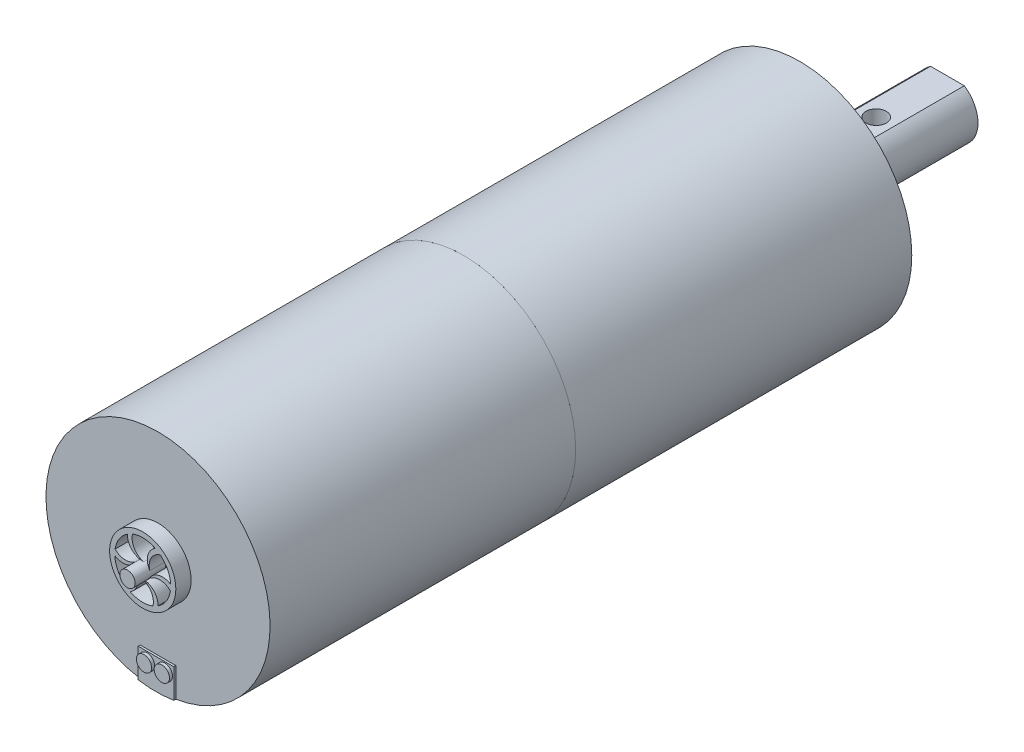
from build123d import *

# Parameters (mm, degrees)
ESQUISSE1_R                  = 11
ESQUISSE1_R_2                = 7.5
ESQUISSE1_R_3                = 1
BOSS_EXTRU_1_DEPTH           = 33
ESQUISSE1_R_4                = 4.25
BOSS_EXTRU_1_2_DEPTH         = 33
ESQUISSE1_3_R                = 4.25
BOSS_EXTRU_2_DEPTH           = 1.5
BOSS_EXTRU_3_DEPTH           = 2.5
BOSS_EXTRU_4_DEPTH           = 14.5
ESQUISSE1_7_R                = 7.5
ESQUISSE1_7_R_2              = 6.25
BOSS_EXTRU_5_DEPTH           = 1.5
ESQUISSE1_6_R                = 6.25
BOSS_EXTRU_6_DEPTH           = 1
ESQUISSE1_8_R                = 4.25
ESQUISSE1_8_R_2              = 3
BOSS_EXTRU_7_DEPTH           = 1.5
ENL_V_MAT_EXTRU_1_REACH      = 39.313
ENL_V_MAT_EXTRU_1_END_RADIUS = 3
ESQUISSE2_R                  = 1
ESQUISSE3_R                  = 11
BOSS_EXTRU_8_DEPTH           = 30
ESQUISSE3_2_R                = 11
BOSS_EXTRU_9_DEPTH           = 27
ESQUISSE4_R                  = 3.25
ESQUISSE4_R_2                = 2.75
BOSS_EXTRU_10_DEPTH          = 1.5
ESQUISSE5_R                  = 0.75
BOSS_EXTRU_11_DEPTH          = 1.5
CHANFREIN1_SIZE              = 0.5
ESQUISSE6_R                  = 0.75
BOSS_EXTRU_15_DEPTH          = 0.2
ESQUISSE6_4_R                = 0.75
BOSS_EXTRU_16_DEPTH          = 0.5
ESQUISSE6_5_R                = 0.75
BOSS_EXTRU_17_DEPTH          = 0.5


with BuildPart() as part:
    # Esquisse1 → Boss.-Extru.1 (new body)
    with BuildSketch(Plane.XY):
        Circle(ESQUISSE1_R)
        Circle(ESQUISSE1_R_2, mode=Mode.SUBTRACT)
        with Locations((0, 9.5)):
            Circle(ESQUISSE1_R_3, mode=Mode.SUBTRACT)
        with Locations((8.227241336, 4.75)):
            Circle(ESQUISSE1_R_3, mode=Mode.SUBTRACT)
        with Locations((8.227241336, -4.75)):
            Circle(ESQUISSE1_R_3, mode=Mode.SUBTRACT)
        with Locations((0, -9.5)):
            Circle(ESQUISSE1_R_3, mode=Mode.SUBTRACT)
        with Locations((-8.227241336, -4.75)):
            Circle(ESQUISSE1_R_3, mode=Mode.SUBTRACT)
        with Locations((-8.227241336, 4.75)):
            Circle(ESQUISSE1_R_3, mode=Mode.SUBTRACT)
    extrude(amount=BOSS_EXTRU_1_DEPTH)

    # Esquisse3_2 → Boss.-Extru.9 (add)
    with BuildSketch(Plane.XY.offset(33)):
        Circle(ESQUISSE3_2_R)
    extrude(amount=-BOSS_EXTRU_9_DEPTH)


with BuildPart() as body_2:
    # Esquisse1 → Boss.-Extru.1 2 (new body)
    with BuildSketch(Plane.XY):
        Circle(ESQUISSE1_R_4)
    extrude(amount=BOSS_EXTRU_1_2_DEPTH)


with BuildPart() as body_3:
    # Esquisse1_3 → Boss.-Extru.2 (new body)
    with BuildSketch(Plane.XY):
        Circle(ESQUISSE1_3_R)
    extrude(amount=-BOSS_EXTRU_2_DEPTH)



with BuildPart() as body_4:
    # Esquisse1_4 → Boss.-Extru.3 (new body)
    with BuildSketch(Plane.XY):
        with BuildLine():
            ThreePointArc((1.658312395, 2.5), (0, 3), (-1.658312395, 2.5))
            Line((-1.658312395, 2.5), (1.658312395, 2.5))
        make_face()
        with BuildLine():
            Line((1.658312395, 2.5), (-1.658312395, 2.5))
            ThreePointArc((-1.658312395, 2.5), (-1.418637165, -2.643382037), (3, 0))
            ThreePointArc((3, 0), (2.643382037, 1.418637165), (1.658312395, 2.5))
        make_face()
    extrude(amount=-BOSS_EXTRU_3_DEPTH)


with BuildPart() as body_5:
    # Esquisse1_5 → Boss.-Extru.4 (new body)
    with BuildSketch(Plane.XY):
        with BuildLine():
            Line((1.658312395, 2.5), (-1.658312395, 2.5))
            ThreePointArc((-1.658312395, 2.5), (-1.418637165, -2.643382037), (3, 0))
            ThreePointArc((3, 0), (2.643382037, 1.418637165), (1.658312395, 2.5))
        make_face()
    extrude(amount=-BOSS_EXTRU_4_DEPTH)


with BuildPart() as body_6:
    # Esquisse1_7 → Boss.-Extru.5 (new body)
    with BuildSketch(Plane.XY):
        Circle(ESQUISSE1_7_R)
        Circle(ESQUISSE1_7_R_2, mode=Mode.SUBTRACT)
    extrude(amount=-BOSS_EXTRU_5_DEPTH)

    # Chanfrein1
    chanfrein1_edges = [body_6.edges().sort_by_distance(p)[0] for p in [
        (-6.25, 0, -1.5),
    ]]
    chamfer(chanfrein1_edges, length=CHANFREIN1_SIZE)


with BuildPart() as body_3_1:
    add(body_3.part)

    add(body_4.part)  # Boss.-Extru.6 merges body 4

    add(body_5.part)  # Boss.-Extru.6 merges body 5

    add(body_2.part)  # Boss.-Extru.6 merges body 2
    # Esquisse1_6 → Boss.-Extru.6 (add)
    with BuildSketch(Plane.XY):
        Circle(ESQUISSE1_6_R)
    extrude(amount=-BOSS_EXTRU_6_DEPTH)

    # Enlèv. mat.-Extru.1: up to this cylinder (the profile starts inside it)
    enl_v_mat_extru_1_end = Plane(origin=(0, 0, -7.5), z_dir=(0, 0, 1)) * Cylinder(ENL_V_MAT_EXTRU_1_END_RADIUS, 85.626, mode=Mode.PRIVATE)
    # Esquisse2 → Enlèv. mat.-Extru.1 (cut, up to the surface)
    with BuildSketch(Plane(origin=(0, 2.5, 0), x_dir=(1, 0, 0), z_dir=(0, 1, 0)), mode=Mode.PRIVATE) as enl_v_mat_extru_1_sk1:
        with Locations(Location((0, 7.5, 0), (0, 0, 270))):
            Circle(ESQUISSE2_R)
    enl_v_mat_extru_1_tool1 = extrude(enl_v_mat_extru_1_sk1.sketch, amount=-ENL_V_MAT_EXTRU_1_REACH, mode=Mode.PRIVATE) & enl_v_mat_extru_1_end
    add(enl_v_mat_extru_1_tool1.solids().sort_by_distance((0, 2.5, -7.5))[0], mode=Mode.SUBTRACT)


with BuildPart() as body_4_2:
    # Esquisse1_8 → Boss.-Extru.7 (new body)
    with BuildSketch(Plane.XY):
        Circle(ESQUISSE1_8_R)
        Circle(ESQUISSE1_8_R_2, mode=Mode.SUBTRACT)
    extrude(amount=BOSS_EXTRU_7_DEPTH)


with BuildPart() as body_5_2:
    # Esquisse3 → Boss.-Extru.8 (new body)
    with BuildSketch(Plane.XY.offset(33)):
        Circle(ESQUISSE3_R)
    extrude(amount=BOSS_EXTRU_8_DEPTH)

    # Esquisse4 → Boss.-Extru.10 (add)
    with BuildSketch(Plane.XY.offset(63)):
        Circle(ESQUISSE4_R)
        Circle(ESQUISSE4_R_2, mode=Mode.SUBTRACT)
        with BuildLine():
            ThreePointArc((2.718363052, -0.415935473), (2.742079356, -0.208568462), (2.75, 0))
            ThreePointArc((2.75, 0), (2.749038607, 0.072709944), (2.746155101, 0.14536905))
            ThreePointArc((2.746155101, 0.14536905), (1.587231065, 0.330830847), (0.649519053, -0.375))
            ThreePointArc((0.649519053, -0.375), (0.748323987, -0.050111984), (0.693719659, 0.285049178))
            ThreePointArc((0.693719659, 0.285049178), (0.820134783, 1.42858113), (1.719392212, 2.146203723))
            ThreePointArc((1.719392212, 2.146203723), (1.491092786, 2.310658414), (1.247184261, 2.450924605))
            ThreePointArc((1.247184261, 2.450924605), (0.507107615, 1.539997847), (0.649519053, 0.375))
            ThreePointArc((0.649519053, 0.375), (0.417560245, 0.62301159), (0.1, 0.743303437))
            ThreePointArc((0.1, 0.743303437), (-0.827120158, 1.424548122), (-0.99897084, 2.562139196))
            ThreePointArc((-0.99897084, 2.562139196), (-1.255542493, 2.446653439), (-1.49897084, 2.305555556))
            ThreePointArc((-1.49897084, 2.305555556), (-1.08012345, 1.209167), (0, 0.75))
            ThreePointArc((0, 0.75), (-0.330763742, 0.673123575), (-0.593719659, 0.458254259))
            ThreePointArc((-0.593719659, 0.458254259), (-1.647254942, -0.004033008), (-2.718363052, 0.415935473))
            ThreePointArc((-2.718363052, 0.415935473), (-2.746635279, 0.135995025), (-2.746155101, -0.14536905))
            ThreePointArc((-2.746155101, -0.14536905), (-1.587231065, -0.330830847), (-0.649519053, 0.375))
            ThreePointArc((-0.649519053, 0.375), (-0.748323987, 0.050111984), (-0.693719659, -0.285049178))
            ThreePointArc((-0.693719659, -0.285049178), (-0.820134783, -1.42858113), (-1.719392212, -2.146203723))
            ThreePointArc((-1.719392212, -2.146203723), (-1.491092786, -2.310658414), (-1.247184261, -2.450924605))
            ThreePointArc((-1.247184261, -2.450924605), (-0.507107615, -1.539997847), (-0.649519053, -0.375))
            ThreePointArc((-0.649519053, -0.375), (-0.417560245, -0.62301159), (-0.1, -0.743303437))
            ThreePointArc((-0.1, -0.743303437), (0.827120158, -1.424548122), (0.99897084, -2.562139196))
            ThreePointArc((0.99897084, -2.562139196), (1.255542493, -2.446653439), (1.49897084, -2.305555556))
            ThreePointArc((1.49897084, -2.305555556), (1.08012345, -1.209167), (0, -0.75))
            ThreePointArc((0, -0.75), (0.330763742, -0.673123575), (0.593719659, -0.458254259))
            ThreePointArc((0.593719659, -0.458254259), (1.647254942, 0.004033008), (2.718363052, -0.415935473))
        make_face()
    extrude(amount=BOSS_EXTRU_10_DEPTH)

    # Esquisse5 → Boss.-Extru.11 (add)
    with BuildSketch(Plane.XY.offset(64.5)):
        with Locations(Location((0, 0, 0), (0, 0, 202.337744339))):
            Circle(ESQUISSE5_R)
    extrude(amount=BOSS_EXTRU_11_DEPTH)

    # Esquisse6 → Boss.-Extru.15 (add)
    with BuildSketch(Plane.XY.offset(63)):
        with BuildLine():
            Line((1.75, -8), (-1.75, -8))
            Line((-1.75, -8), (-1.75, -10.859903314))
            ThreePointArc((-1.75, -10.859903314), (0, -11), (1.75, -10.859903314))
            Line((1.75, -10.859903314), (1.75, -8))
        make_face()
        with Locations((-0.875, -8.875)):
            Circle(ESQUISSE6_R, mode=Mode.SUBTRACT)
        with Locations(Location((0.875, -8.875, 0), (0, 0, 180))):
            Circle(ESQUISSE6_R, mode=Mode.SUBTRACT)
    extrude(amount=BOSS_EXTRU_15_DEPTH)

    # Esquisse6_4 → Boss.-Extru.16 (add)
    with BuildSketch(Plane.XY.offset(63)):
        with Locations((-0.875, -8.875)):
            Circle(ESQUISSE6_4_R)
    extrude(amount=BOSS_EXTRU_16_DEPTH)

    # Esquisse6_5 → Boss.-Extru.17 (add)
    with BuildSketch(Plane.XY.offset(63)):
        with Locations(Location((0.875, -8.875, 0), (0, 0, 180))):
            Circle(ESQUISSE6_5_R)
    extrude(amount=BOSS_EXTRU_17_DEPTH)


solid = Compound([part.part, body_6.part, body_3_1.part, body_4_2.part, body_5_2.part])
